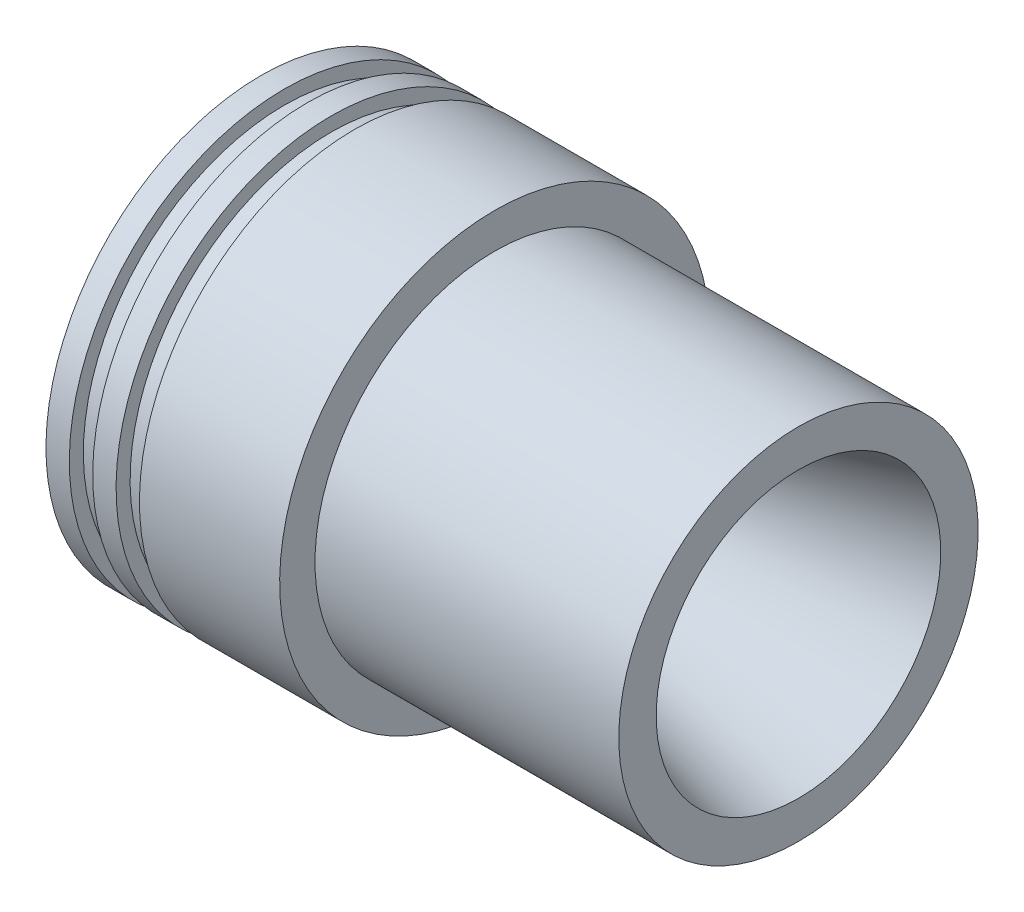
from build123d import *


with BuildPart() as part:
    # Sketch1 → Revolve1 (revolve)
    with BuildSketch(Plane.XY):
        Polygon((-115, 36.5), (-71.698729811, 11.5), (-70.698729811, 11.5), (0, 30.443667559), (0, 38.443667559), (-65, 38.443667559), (-65, 46), (-95, 46), (-95, 43), (-100, 43), (-100, 46), (-105, 46), (-105, 43), (-110, 43), (-110, 46), (-115, 46), align=None)
    revolve(axis=Axis((0, 0, 0), (-1, 0, 0)))


solid = part.part
